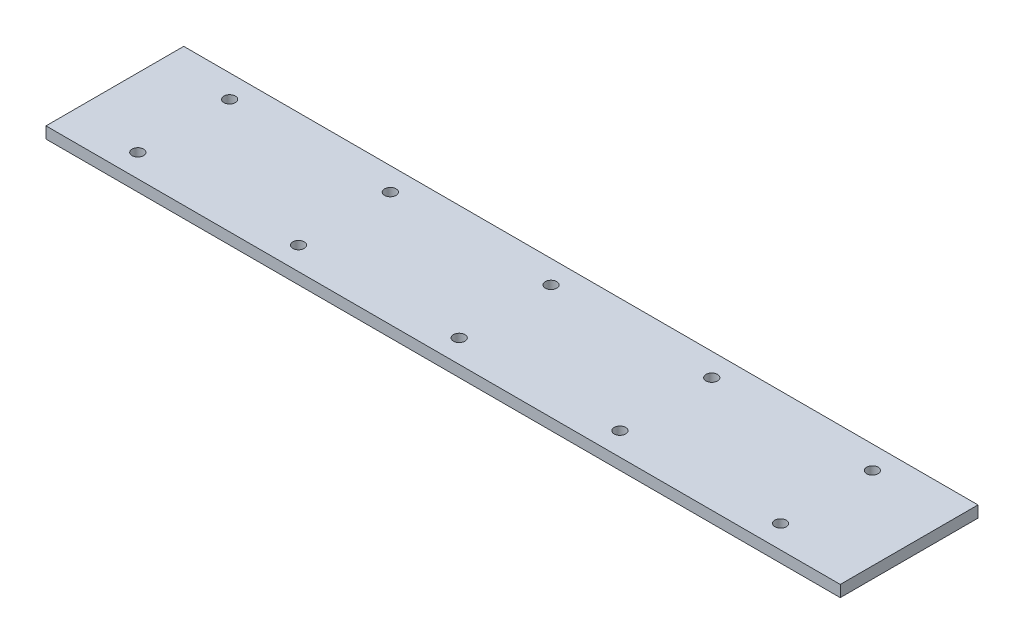
from build123d import *

# Parameters (mm, degrees)
SKETCH1_W           = 346
SKETCH1_H           = 60
SKETCH1_R           = 2.5
BOSS_EXTRUDE1_DEPTH = 5


with BuildPart() as part:
    # Sketch1 → Boss-Extrude1 (new body)
    with BuildSketch(Plane(origin=(0, 0, 0), x_dir=(1, 0, 0), z_dir=(0, 1, 0))):
        with Locations((173, 30)):
            Rectangle(SKETCH1_W, SKETCH1_H)
        with Locations((30, 50)):
            Circle(SKETCH1_R, mode=Mode.SUBTRACT)
        with Locations((100, 50)):
            Circle(SKETCH1_R, mode=Mode.SUBTRACT)
        with Locations((170, 50)):
            Circle(SKETCH1_R, mode=Mode.SUBTRACT)
        with Locations((240, 50)):
            Circle(SKETCH1_R, mode=Mode.SUBTRACT)
        with Locations((310, 50)):
            Circle(SKETCH1_R, mode=Mode.SUBTRACT)
        with Locations((310, 10)):
            Circle(SKETCH1_R, mode=Mode.SUBTRACT)
        with Locations((240, 10)):
            Circle(SKETCH1_R, mode=Mode.SUBTRACT)
        with Locations((170, 10)):
            Circle(SKETCH1_R, mode=Mode.SUBTRACT)
        with Locations((100, 10)):
            Circle(SKETCH1_R, mode=Mode.SUBTRACT)
        with Locations((30, 10)):
            Circle(SKETCH1_R, mode=Mode.SUBTRACT)
    extrude(amount=BOSS_EXTRUDE1_DEPTH)


solid = part.part
